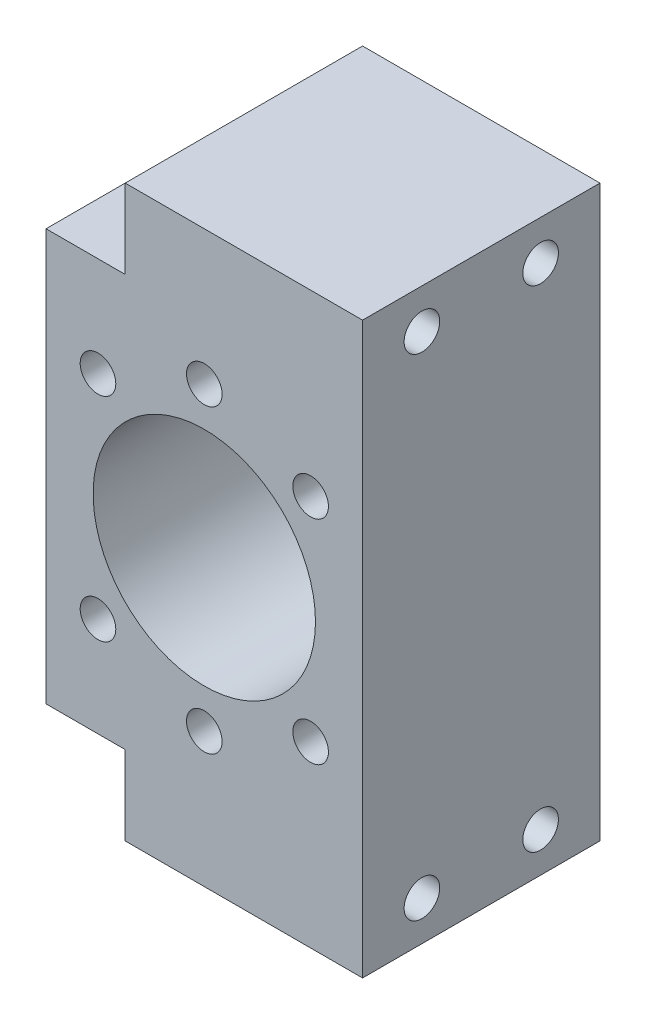
from build123d import *

# Parameters (mm, degrees)
SKETCH2_R          = 2.25
SKETCH2_R_2        = 14.05
EXTRUDE6_DEPTH     = 30
CUT_EXTRUDE1_DEPTH = 30
SKETCH4_W          = 30
SKETCH4_H          = 10
CUT_EXTRUDE2_DEPTH = 10


with BuildPart() as part:
    # Sketch2 → Extrude6 (new body)
    with BuildSketch(Plane.XY.offset(10)):
        Polygon((20, 0), (20, -36), (-20, -36), (-20, 36), (20, 36), align=None)
        with Locations((13.435028843, 13.435028843)):
            Circle(SKETCH2_R, mode=Mode.SUBTRACT)
        with Locations((0, 19)):
            Circle(SKETCH2_R, mode=Mode.SUBTRACT)
        with Locations((-13.435028843, 13.435028843)):
            Circle(SKETCH2_R, mode=Mode.SUBTRACT)
        with Locations((-13.435028843, -13.435028843)):
            Circle(SKETCH2_R, mode=Mode.SUBTRACT)
        with Locations((0, -19)):
            Circle(SKETCH2_R, mode=Mode.SUBTRACT)
        with Locations((13.435028843, -13.435028843)):
            Circle(SKETCH2_R, mode=Mode.SUBTRACT)
        Circle(SKETCH2_R_2, mode=Mode.SUBTRACT)
    extrude(amount=EXTRUDE6_DEPTH)

    # Sketch3 → Cut-Extrude1 (cut)
    with BuildSketch(Plane(origin=(20, 0, 0), x_dir=(0, 0, -1), z_dir=(1, 0, 0))):
        with BuildLine():
            ThreePointArc((-30.25, 31), (-30.909009742, 32.590990258), (-32.5, 33.25))
            Line((-32.5, 33.25), (-32.5, 31))
            Line((-32.5, 31), (-32.5, 28.75))
            ThreePointArc((-32.5, 28.75), (-30.909009742, 29.409009742), (-30.25, 31))
        make_face()
        with BuildLine():
            Line((-32.5, 31), (-32.5, 33.25))
            ThreePointArc((-32.5, 33.25), (-34.75, 31), (-32.5, 28.75))
            Line((-32.5, 28.75), (-32.5, 31))
        make_face()
        with BuildLine():
            ThreePointArc((-30.25, 31), (-30.909009742, 32.590990258), (-32.5, 33.25))
            Line((-32.5, 33.25), (-32.5, 31))
            Line((-32.5, 31), (-32.5, 28.75))
            ThreePointArc((-32.5, 28.75), (-30.909009742, 29.409009742), (-30.25, 31))
        make_face()
        with BuildLine():
            Line((-32.5, 31), (-32.5, 33.25))
            ThreePointArc((-32.5, 33.25), (-34.75, 31), (-32.5, 28.75))
            Line((-32.5, 28.75), (-32.5, 31))
        make_face()
        with BuildLine():
            ThreePointArc((-15.25, 31), (-15.909009742, 32.590990258), (-17.5, 33.25))
            Line((-17.5, 33.25), (-17.5, 31))
            Line((-17.5, 31), (-17.5, 28.75))
            ThreePointArc((-17.5, 28.75), (-15.909009742, 29.409009742), (-15.25, 31))
        make_face()
        with BuildLine():
            Line((-17.5, 31), (-17.5, 33.25))
            ThreePointArc((-17.5, 33.25), (-19.75, 31), (-17.5, 28.75))
            Line((-17.5, 28.75), (-17.5, 31))
        make_face()
        with BuildLine():
            ThreePointArc((-30.25, -31), (-30.909009742, -29.409009742), (-32.5, -28.75))
            Line((-32.5, -28.75), (-32.5, -31))
            Line((-32.5, -31), (-32.5, -33.25))
            ThreePointArc((-32.5, -33.25), (-30.909009742, -32.590990258), (-30.25, -31))
        make_face()
        with BuildLine():
            Line((-32.5, -31), (-32.5, -28.75))
            ThreePointArc((-32.5, -28.75), (-34.75, -31), (-32.5, -33.25))
            Line((-32.5, -33.25), (-32.5, -31))
        make_face()
        with BuildLine():
            ThreePointArc((-30.25, -31), (-30.909009742, -29.409009742), (-32.5, -28.75))
            Line((-32.5, -28.75), (-32.5, -31))
            Line((-32.5, -31), (-32.5, -33.25))
            ThreePointArc((-32.5, -33.25), (-30.909009742, -32.590990258), (-30.25, -31))
        make_face()
        with BuildLine():
            Line((-32.5, -31), (-32.5, -28.75))
            ThreePointArc((-32.5, -28.75), (-34.75, -31), (-32.5, -33.25))
            Line((-32.5, -33.25), (-32.5, -31))
        make_face()
        with BuildLine():
            ThreePointArc((-15.25, -31), (-15.909009742, -29.409009742), (-17.5, -28.75))
            Line((-17.5, -28.75), (-17.5, -31))
            Line((-17.5, -31), (-17.5, -33.25))
            ThreePointArc((-17.5, -33.25), (-15.909009742, -32.590990258), (-15.25, -31))
        make_face()
        with BuildLine():
            Line((-17.5, -31), (-17.5, -28.75))
            ThreePointArc((-17.5, -28.75), (-19.75, -31), (-17.5, -33.25))
            Line((-17.5, -33.25), (-17.5, -31))
        make_face()
        with BuildLine():
            ThreePointArc((-15.25, -31), (-15.909009742, -29.409009742), (-17.5, -28.75))
            Line((-17.5, -28.75), (-17.5, -31))
            Line((-17.5, -31), (-17.5, -33.25))
            ThreePointArc((-17.5, -33.25), (-15.909009742, -32.590990258), (-15.25, -31))
        make_face()
        with BuildLine():
            Line((-17.5, -31), (-17.5, -28.75))
            ThreePointArc((-17.5, -28.75), (-19.75, -31), (-17.5, -33.25))
            Line((-17.5, -33.25), (-17.5, -31))
        make_face()
    extrude(amount=-CUT_EXTRUDE1_DEPTH, mode=Mode.SUBTRACT)

    # Sketch4 → Cut-Extrude2 (cut)
    with BuildSketch(Plane.ZY.offset(20)):
        with Locations((25, 31)):
            Rectangle(SKETCH4_W, SKETCH4_H)
        with Locations((25, -31)):
            Rectangle(SKETCH4_W, SKETCH4_H)
    extrude(amount=-CUT_EXTRUDE2_DEPTH, mode=Mode.SUBTRACT)


solid = part.part
